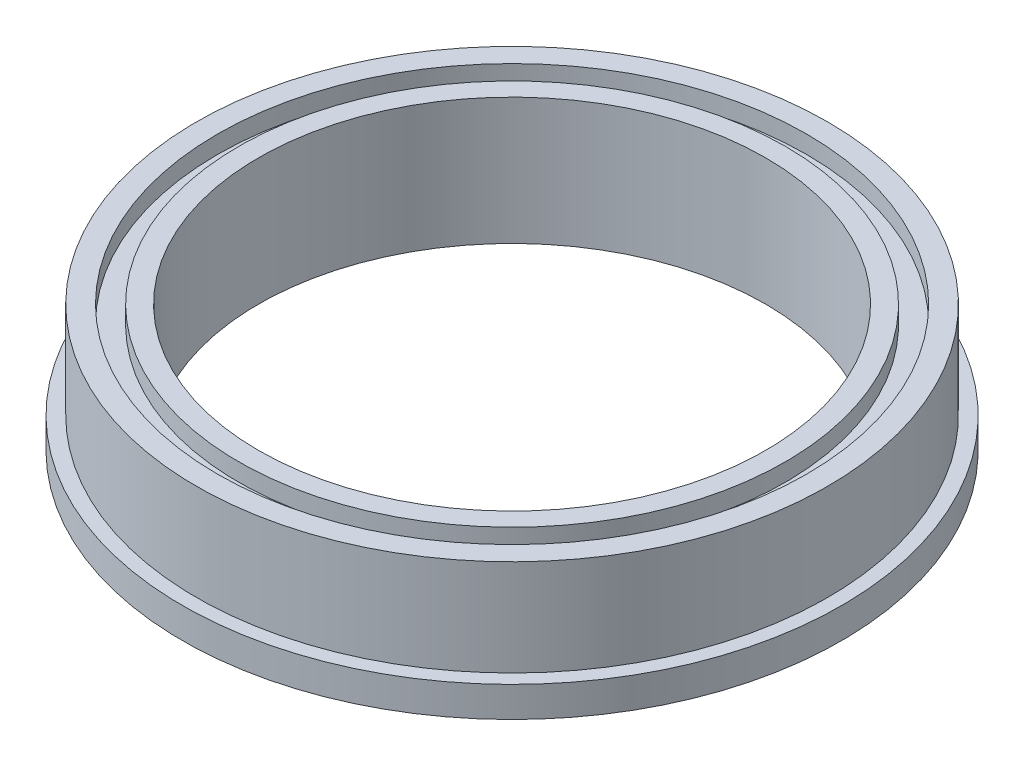
from build123d import *


with BuildPart() as part:
    # Sketch1 → Revolve1 (revolve)
    with BuildSketch(Plane.XY):
        Polygon((16.51, 0), (16.51, 1.524), (15.8115, 1.524), (15.8115, 6.35), (14.7574, 6.35), (14.7574, 5.461), (13.6906, 5.461), (13.6906, 6.35), (12.7, 6.35), (12.7, 0), (13.6906, 0), (13.6906, 0.889), (14.7574, 0.889), (14.7574, 0), align=None)
    revolve(axis=Axis((0, 6.35, 0), (0, -1, 0)))


solid = part.part
